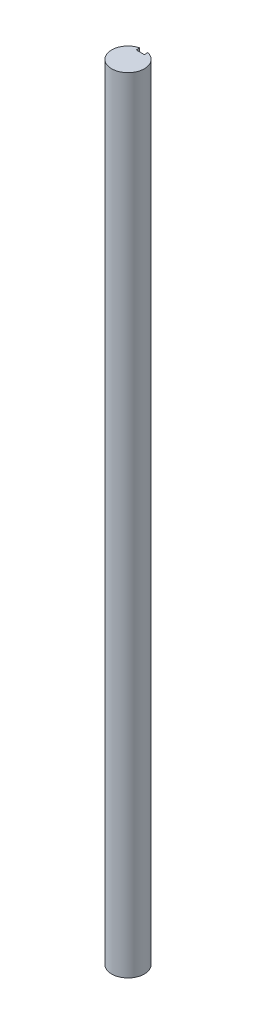
from build123d import *

# Parameters (mm, degrees)
EXTRUDE1_DEPTH = 304.8


with BuildPart() as part:
    # Sketch1 → Extrude1 (new body)
    with BuildSketch(Plane(origin=(0, 0, 0), x_dir=(1, 0, 0), z_dir=(0, 1, 0))):
        with BuildLine():
            Line((-1.5875, 6.148361062), (-1.5875, 4.7625))
            Line((-1.5875, 4.7625), (1.5875, 4.7625))
            Line((1.5875, 4.7625), (1.5875, 6.148361062))
            ThreePointArc((1.5875, 6.148361062), (0, -6.35), (-1.5875, 6.148361062))
        make_face()
    extrude(amount=EXTRUDE1_DEPTH)


solid = part.part
